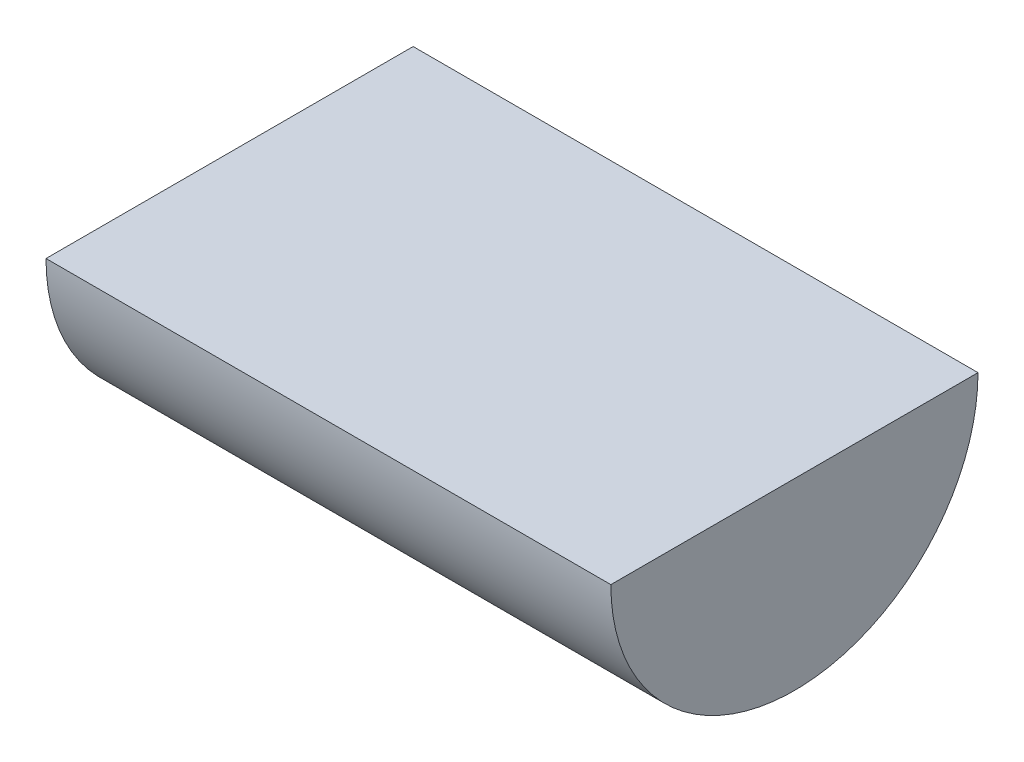
from build123d import *

# Parameters (mm, degrees)
SKETCH1_R           = 19.5
BOSS_EXTRUDE1_DEPTH = 60
SKETCH2_W           = 45.508143675
SKETCH2_H           = 21.045075026
CUT_EXTRUDE1_DEPTH  = 75


with BuildPart() as part:
    # Sketch1 → Boss-Extrude1 (new body)
    with BuildSketch(Plane(origin=(0, 0, 0), x_dir=(0, 0, -1), z_dir=(1, 0, 0))):
        Circle(SKETCH1_R)
    extrude(amount=BOSS_EXTRUDE1_DEPTH)

    # Sketch2 → Cut-Extrude1 (cut)
    with BuildSketch(Plane(origin=(0, 0, 0), x_dir=(0, 0, -1), z_dir=(1, 0, 0))):
        with Locations((-1.204435848, 10.522537513)):
            Rectangle(SKETCH2_W, SKETCH2_H)
    extrude(amount=CUT_EXTRUDE1_DEPTH, mode=Mode.SUBTRACT)


solid = part.part
